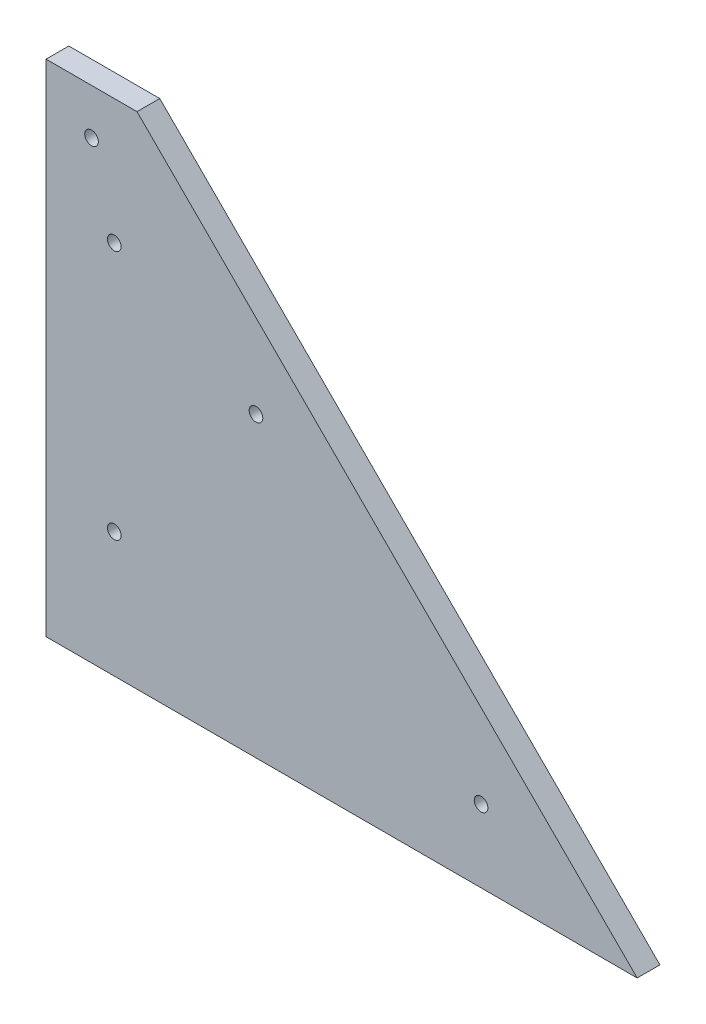
from build123d import *

# Parameters (mm, degrees)
BOSS_EXTRUDE1_DEPTH = 5
SKETCH2_R           = 1.5
CUT_EXTRUDE1_DEPTH  = 6
SKETCH3_R           = 1.5
CUT_EXTRUDE2_DEPTH  = 6
SKETCH4_R           = 1.5
CUT_EXTRUDE3_DEPTH  = 6


with BuildPart() as part:
    # Sketch1 → Boss-Extrude1 (new body)
    with BuildSketch(Plane.XY):
        Polygon((0, 0), (0, 110), (20, 110), (130, 0), align=None)
    extrude(amount=BOSS_EXTRUDE1_DEPTH)

    # Sketch2 → Cut-Extrude1 (cut, through all)
    with BuildSketch(Plane.XY.offset(5)):
        with Locations((15, 82.5)):
            Circle(SKETCH2_R)
        with Locations((15, 27.5)):
            Circle(SKETCH2_R)
    extrude(amount=-CUT_EXTRUDE1_DEPTH, mode=Mode.SUBTRACT)

    # Sketch3 → Cut-Extrude2 (cut, through all)
    with BuildSketch(Plane.XY.offset(5)):
        with Locations((46.162950904, 65.452272785)):
            Circle(SKETCH3_R)
        with Locations((95.660425587, 15.954798102)):
            Circle(SKETCH3_R)
    extrude(amount=-CUT_EXTRUDE2_DEPTH, mode=Mode.SUBTRACT)

    # Sketch4 → Cut-Extrude3 (cut, through all)
    with BuildSketch(Plane.XY.offset(5)):
        with Locations((10, 100)):
            Circle(SKETCH4_R)
    extrude(amount=-CUT_EXTRUDE3_DEPTH, mode=Mode.SUBTRACT)


solid = part.part
